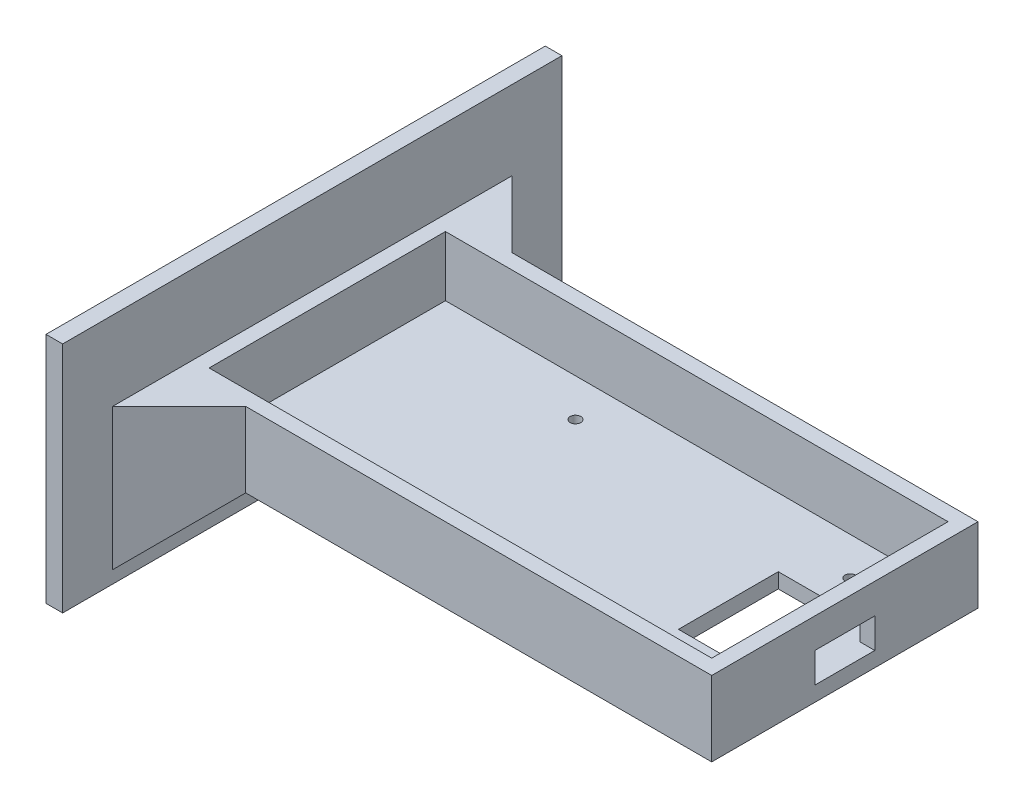
from build123d import *

# Parameters (mm, degrees)
SKETCH1_W           = 160
SKETCH1_H           = 80
BOSS_EXTRUDE1_DEPTH = 22.5
SKETCH2_W           = 151
SKETCH2_H           = 71
CUT_EXTRUDE1_DEPTH  = 18
SKETCH3_W           = 150
SKETCH3_H           = 70
BOSS_EXTRUDE2_DEPTH = 5
SKETCH4_W           = 18
SKETCH4_H           = 9
CUT_EXTRUDE3_DEPTH  = 13
SKETCH6_R           = 1.6
CUT_EXTRUDE5_DEPTH  = 13
SKETCH5_W           = 25
SKETCH5_H           = 30
CUT_EXTRUDE6_DEPTH  = 13
CHAMFER3_SIZE       = 20


with BuildPart() as part:
    # Sketch1 → Boss-Extrude1 (new body)
    with BuildSketch(Plane(origin=(0, 0, 0), x_dir=(1, 0, 0), z_dir=(0, 1, 0))):
        Rectangle(SKETCH1_W, SKETCH1_H)
    extrude(amount=BOSS_EXTRUDE1_DEPTH)

    # Sketch2 → Cut-Extrude1 (cut)
    with BuildSketch(Plane(origin=(0, 22.5, 0), x_dir=(1, 0, 0), z_dir=(0, 1, 0))):
        Rectangle(SKETCH2_W, SKETCH2_H)
    extrude(amount=-CUT_EXTRUDE1_DEPTH, mode=Mode.SUBTRACT)

    # Sketch3 → Boss-Extrude2 (add)
    with BuildSketch(Plane.ZY.offset(80)):
        with Locations((0, 11.25)):
            Rectangle(SKETCH3_W, SKETCH3_H)
    extrude(amount=BOSS_EXTRUDE2_DEPTH)

    # Sketch4 → Cut-Extrude3 (cut)
    with BuildSketch(Plane(origin=(80, 0, 0), x_dir=(0, 0, -1), z_dir=(1, 0, 0))):
        with Locations((0, 9)):
            Rectangle(SKETCH4_W, SKETCH4_H)
    extrude(amount=-CUT_EXTRUDE3_DEPTH, mode=Mode.SUBTRACT)

    # Sketch6 → Cut-Extrude5 (cut)
    with BuildSketch(Plane(origin=(0, 4.5, 0), x_dir=(1, 0, 0), z_dir=(0, 1, 0))):
        with Locations((57.5, 24.14)):
            Circle(SKETCH6_R)
        with Locations((56.23, -24.12)):
            Circle(SKETCH6_R)
        with Locations((-18.7, -24.14)):
            Circle(SKETCH6_R)
        with Locations((-25.05, 24.12)):
            Circle(SKETCH6_R)
    extrude(amount=-CUT_EXTRUDE5_DEPTH, mode=Mode.SUBTRACT)

    # Sketch5 → Cut-Extrude6 (cut)
    with BuildSketch(Plane.XZ):
        with Locations((57.5, 0)):
            Rectangle(SKETCH5_W, SKETCH5_H)
    extrude(amount=-CUT_EXTRUDE6_DEPTH, mode=Mode.SUBTRACT)

    # Chamfer3
    chamfer3_edges = [part.edges().sort_by_distance(p)[0] for p in [
        (-80, 0, 0),
        (-80, 11.25, 40),
        (-80, 11.25, -40),
    ]]
    chamfer(chamfer3_edges, length=CHAMFER3_SIZE)


solid = part.part
